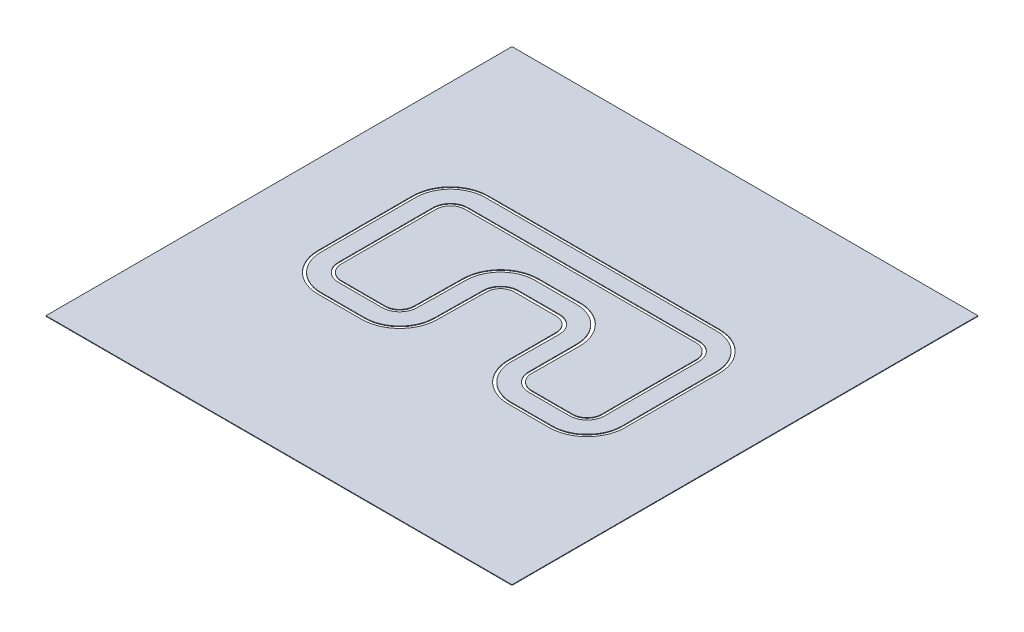
from build123d import *

# Parameters (mm, degrees)
SKETCH1_W             = 8000
SKETCH1_H             = 8000
BOSS_EXTRUDE1_DEPTH   = 10
BOSS_EXTRUDE1_2_DEPTH = 10
BOSS_EXTRUDE1_3_DEPTH = 10


with BuildPart() as part:
    # Sketch1 → Boss-Extrude1 (new body)
    with BuildSketch(Plane(origin=(0, 0, 0), x_dir=(1, 0, 0), z_dir=(0, 1, 0))):
        Rectangle(SKETCH1_W, SKETCH1_H)
        with BuildLine():
            Line((-332.440811098, 372.812938413), (381.518586898, 372.812938413))
            ThreePointArc((381.518586898, 372.812938413), (555.976577605, 302.056472372), (627.732993812, 128.007385212))
            Line((627.732993812, 128.007385212), (627.732993812, -694.515046657))
            ThreePointArc((627.732993812, -694.515046657), (821.44963805, -1154.417175641), (1282.87647146, -1344.473440754))
            Line((1282.87647146, -1344.473440754), (1984.511930504, -1344.473440754))
            ThreePointArc((1984.511930504, -1344.473440754), (2444.131338275, -1154.092848525), (2634.511930504, -694.473440754))
            Line((2634.511930504, -694.473440754), (2634.511930504, 128.048991114))
            Line((2634.511930504, 128.048991114), (2634.511930504, 928.048991114))
            ThreePointArc((2634.511930504, 928.048991114), (2444.131338275, 1387.668398886), (1984.511930504, 1578.048991114))
            Line((1984.511930504, 1578.048991114), (-1984.511930504, 1578.048991114))
            ThreePointArc((-1984.511930504, 1578.048991114), (-2444.131338275, 1387.668398886), (-2634.511930504, 928.048991114))
            Line((-2634.511930504, 928.048991114), (-2634.511930504, 128.048991114))
            Line((-2634.511930504, 128.048991114), (-2634.511930504, -694.473440754))
            ThreePointArc((-2634.511930504, -694.473440754), (-2444.131338275, -1154.092848525), (-1984.511930504, -1344.473440754))
            Line((-1984.511930504, -1344.473440754), (-1233.309703409, -1344.473440754))
            ThreePointArc((-1233.309703409, -1344.473440754), (-773.690295638, -1154.092848525), (-583.309703409, -694.473440754))
            Line((-583.309703409, -694.473440754), (-572.420179467, 135.959803133))
            ThreePointArc((-572.420179467, 135.959803133), (-501.030182749, 303.62752727), (-332.440811098, 372.812938413))
        make_face(mode=Mode.SUBTRACT)
    extrude(amount=BOSS_EXTRUDE1_DEPTH)


with BuildPart() as body_2:
    # Sketch1 → Boss-Extrude1 2 (new body)
    with BuildSketch(Plane(origin=(0, 0, 0), x_dir=(1, 0, 0), z_dir=(0, 1, 0))):
        with BuildLine():
            ThreePointArc((-322.491680317, 428.540285438), (-533.22839488, 342.058521509), (-622.465890777, 132.473866338))
            Line((-622.465890777, 132.473866338), (-633.309703409, -694.473440754))
            ThreePointArc((-633.309703409, -694.473440754), (-809.045634697, -1118.737509466), (-1233.309703409, -1294.473440754))
            Line((-1233.309703409, -1294.473440754), (-1984.511930504, -1294.473440754))
            ThreePointArc((-1984.511930504, -1294.473440754), (-2408.775999216, -1118.737509466), (-2584.511930504, -694.473440754))
            Line((-2584.511930504, -694.473440754), (-2584.511930504, 128.048991114))
            Line((-2584.511930504, 128.048991114), (-2584.511930504, 928.048991114))
            ThreePointArc((-2584.511930504, 928.048991114), (-2408.775999216, 1352.313059826), (-1984.511930504, 1528.048991114))
            Line((-1984.511930504, 1528.048991114), (1984.511930504, 1528.048991114))
            ThreePointArc((1984.511930504, 1528.048991114), (2408.775999216, 1352.313059826), (2584.511930504, 928.048991114))
            Line((2584.511930504, 928.048991114), (2584.511930504, 128.048991114))
            Line((2584.511930504, 128.048991114), (2584.511930504, -694.473440754))
            ThreePointArc((2584.511930504, -694.473440754), (2408.775999216, -1118.737509466), (1984.511930504, -1294.473440754))
            Line((1984.511930504, -1294.473440754), (1282.898506005, -1294.473440754))
            ThreePointArc((1282.898506005, -1294.473440754), (856.798331797, -1119.054647069), (677.734345793, -694.473440991))
            Line((677.734345793, -694.473440991), (683.447655029, 128.048977101))
            ThreePointArc((683.447655029, 128.048977101), (595.870328955, 340.95505197), (382.967506906, 428.540285438))
            Line((382.967506906, 428.540285438), (-322.491680317, 428.540285438))
        make_face()
        with BuildLine():
            Line((-1984.511930504, 1228.048991114), (1984.511930504, 1228.048991114))
            ThreePointArc((1984.511930504, 1228.048991114), (2196.64396486, 1140.18102547), (2284.511930504, 928.048991114))
            Line((2284.511930504, 928.048991114), (2284.511930504, 128.048991114))
            Line((2284.511930504, 128.048991114), (2284.511930504, -694.473440754))
            ThreePointArc((2284.511930504, -694.473440754), (2196.64396486, -906.60547511), (1984.511930504, -994.473440754))
            Line((1984.511930504, -994.473440754), (1282.898506005, -994.473440754))
            ThreePointArc((1282.898506005, -994.473440754), (1067.100614733, -905.100718615), (977.712310853, -689.309281182))
            Line((977.712310853, -689.309281182), (977.712310853, 133.213150686))
            ThreePointArc((977.712310853, 133.213150686), (802.123284212, 550.858545051), (382.969049813, 722.814671712))
            Line((382.969049813, 722.814671712), (-276.535170431, 722.814671712))
            ThreePointArc((-276.535170431, 722.814671712), (-728.936594404, 565.983819508), (-922.523914451, 128.04899087))
            Line((-922.523914451, 128.04899087), (-933.309703409, -694.473440754))
            ThreePointArc((-933.309703409, -694.473440754), (-1021.177669053, -906.60547511), (-1233.309703409, -994.473440754))
            Line((-1233.309703409, -994.473440754), (-1984.511930504, -994.473440754))
            ThreePointArc((-1984.511930504, -994.473440754), (-2196.64396486, -906.60547511), (-2284.511930504, -694.473440754))
            Line((-2284.511930504, -694.473440754), (-2284.511930504, 128.048991114))
            Line((-2284.511930504, 128.048991114), (-2284.511930504, 928.048991114))
            ThreePointArc((-2284.511930504, 928.048991114), (-2196.64396486, 1140.18102547), (-1984.511930504, 1228.048991114))
        make_face(mode=Mode.SUBTRACT)
    extrude(amount=BOSS_EXTRUDE1_2_DEPTH)


with BuildPart() as body_3:
    # Sketch1 → Boss-Extrude1 3 (new body)
    with BuildSketch(Plane(origin=(0, 0, 0), x_dir=(1, 0, 0), z_dir=(0, 1, 0))):
        with BuildLine():
            ThreePointArc((1984.511930504, 1178.048991114), (2161.2886258, 1104.825686411), (2234.511930504, 928.048991114))
            Line((2234.511930504, 928.048991114), (2234.511930504, 128.048991114))
            Line((2234.511930504, 128.048991114), (2234.511930504, -694.473440754))
            ThreePointArc((2234.511930504, -694.473440754), (2161.2886258, -871.250136051), (1984.511930504, -944.473440754))
            Line((1984.511930504, -944.473440754), (1282.898506005, -944.473440754))
            ThreePointArc((1282.898506005, -944.473440754), (1102.455953711, -869.745379639), (1027.712310697, -689.309281184))
            Line((1027.712310697, -689.309281184), (1032.898506005, 128.048990878))
            ThreePointArc((1032.898506005, 128.048990878), (826.927169977, 603.551397866), (338.393858854, 776.357457486))
            Line((338.393858854, 776.357457486), (-322.409238813, 776.357457486))
            ThreePointArc((-322.409238813, 776.357457486), (-781.53063335, 586.590764344), (-972.523914451, 127.978270706))
            Line((-972.523914451, 127.978270706), (-983.309703409, -694.473440754))
            ThreePointArc((-983.309703409, -694.473440754), (-1056.533008112, -871.250136051), (-1233.309703409, -944.473440754))
            Line((-1233.309703409, -944.473440754), (-1984.511930504, -944.473440754))
            ThreePointArc((-1984.511930504, -944.473440754), (-2161.2886258, -871.250136051), (-2234.511930504, -694.473440754))
            Line((-2234.511930504, -694.473440754), (-2234.511930504, 128.048991114))
            Line((-2234.511930504, 128.048991114), (-2234.511930504, 928.048991114))
            ThreePointArc((-2234.511930504, 928.048991114), (-2161.2886258, 1104.825686411), (-1984.511930504, 1178.048991114))
            Line((-1984.511930504, 1178.048991114), (1984.511930504, 1178.048991114))
        make_face()
    extrude(amount=BOSS_EXTRUDE1_3_DEPTH)


solid = Compound([part.part, body_2.part, body_3.part])
